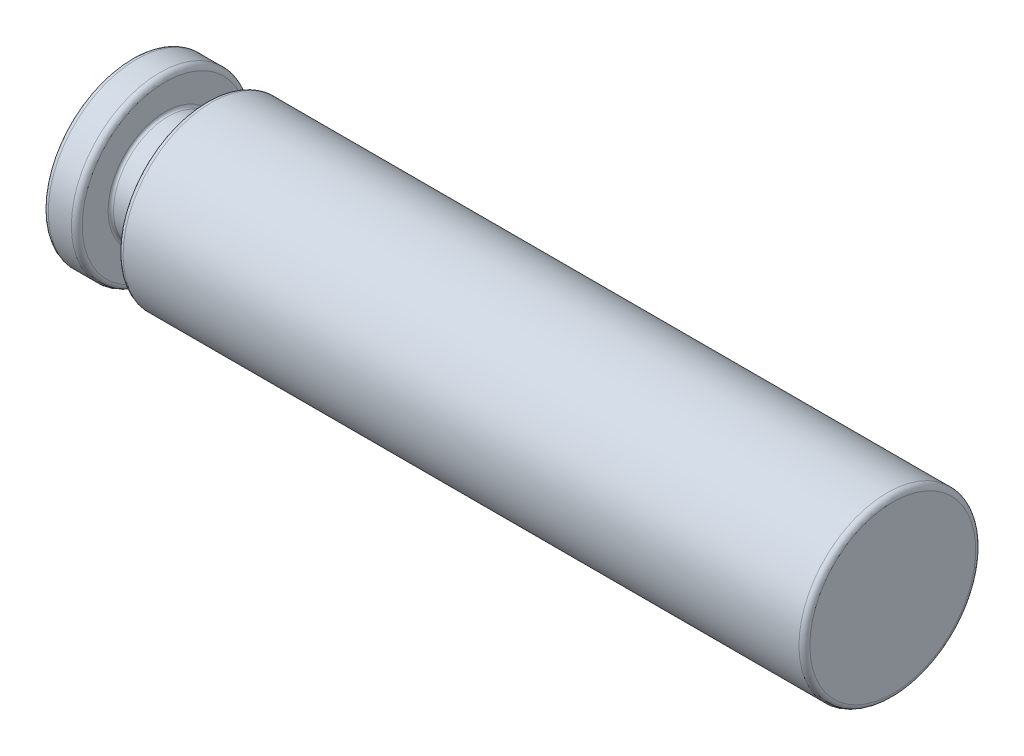
from build123d import *


with BuildPart() as part:
    # Sketch1 → Base-Revolve (revolve)
    with BuildSketch(Plane.XY):
        with BuildLine():
            Line((0, 0), (0, 12.2))
            ThreePointArc((0, 12.2), (0.234314575, 12.765685425), (0.8, 13))
            Line((0.8, 13), (4.2, 13))
            ThreePointArc((4.2, 13), (4.765685425, 12.765685425), (5, 12.2))
            Line((5, 12.2), (5, 8.4))
            ThreePointArc((5, 8.4), (5.117157288, 8.117157288), (5.4, 8))
            Line((5.4, 8), (10.6, 8))
            ThreePointArc((10.6, 8), (10.882842712, 8.117157288), (11, 8.4))
            Line((11, 8.4), (11, 12.2))
            ThreePointArc((11, 12.2), (11.234314575, 12.765685425), (11.8, 13))
            Line((11.8, 13), (111.2, 13))
            ThreePointArc((111.2, 13), (111.765685425, 12.765685425), (112, 12.2))
            Line((112, 12.2), (112, 0))
            Line((112, 0), (0, 0))
        make_face()
    revolve(axis=Axis((0, 0, 0), (1, 0, 0)))


solid = part.part
